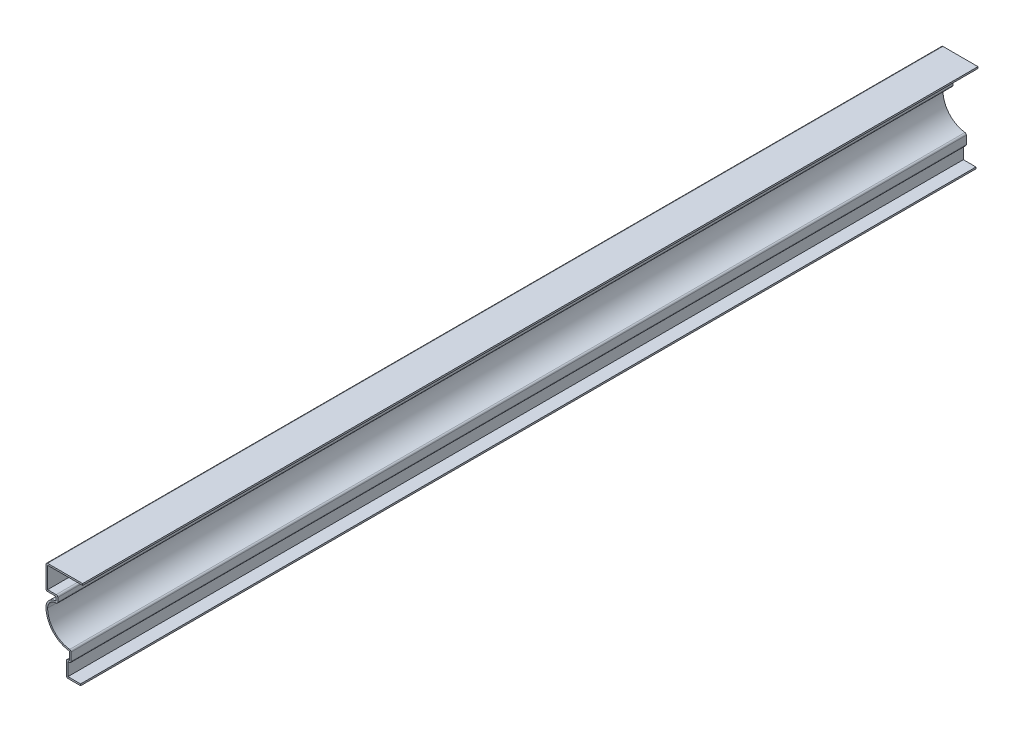
from build123d import *

# Parameters (mm, degrees)
EXTRUDE_THIN1_DEPTH = 698.5
FILLET2_R           = 1.27


with BuildPart() as part:
    # Sketch1 → Extrude-Thin1 (new body)
    with BuildSketch(Plane.XY):
        with BuildLine():
            Line((0, 0), (-11.1125, 0))
            Line((-11.1125, 0), (-11.1125, 12.7))
            Line((-11.1125, 12.7), (-8.73125, 12.7))
            Line((-8.73125, 12.7), (-8.73125, 19.05))
            ThreePointArc((-8.73125, 19.05), (-21.768435997, 25.910734502), (-26.9875, 39.6875))
            ThreePointArc((-26.9875, 39.6875), (-24.662660076, 45.300160076), (-19.05, 47.625))
            Line((-19.05, 47.625), (-19.05, 50.8))
            Line((-19.05, 50.8), (-26.9875, 50.8))
            Line((-26.9875, 50.8), (-26.9875, 69.85))
            Line((-26.9875, 69.85), (1.5875, 69.85))
            Line((1.5875, 69.85), (1.5875, 68.58))
            Line((1.5875, 68.58), (-25.7175, 68.58))
            Line((-25.7175, 68.58), (-25.7175, 52.07))
            Line((-25.7175, 52.07), (-17.78, 52.07))
            Line((-17.78, 52.07), (-17.78, 46.232930181))
            ThreePointArc((-17.78, 46.232930181), (-23.291923576, 44.831587929), (-25.7175, 39.6875))
            ThreePointArc((-25.7175, 39.6875), (-20.440161015, 26.338097436), (-7.46125, 20.205828325))
            Line((-7.46125, 20.205828325), (-7.46125, 11.43))
            Line((-7.46125, 11.43), (-9.8425, 11.43))
            Line((-9.8425, 11.43), (-9.8425, 1.27))
            Line((-9.8425, 1.27), (0, 1.27))
            Line((0, 1.27), (0, 0))
        make_face()
    extrude(amount=-EXTRUDE_THIN1_DEPTH)

    # Fillet2
    fillet2_edges = [part.edges().sort_by_distance(p)[0] for p in [
        (-17.78, 52.07, -349.25),
        (-17.78, 46.232930181, -349.25),
        (-7.46125, 20.205828325, -349.25),
        (-7.46125, 11.43, -349.25),
        (-11.1125, 0, -349.25),
        (-11.1125, 12.7, -349.25),
        (-26.9875, 50.8, -349.25),
        (-26.9875, 69.85, -349.25),
    ]]
    fillet(fillet2_edges, radius=FILLET2_R)


solid = part.part
